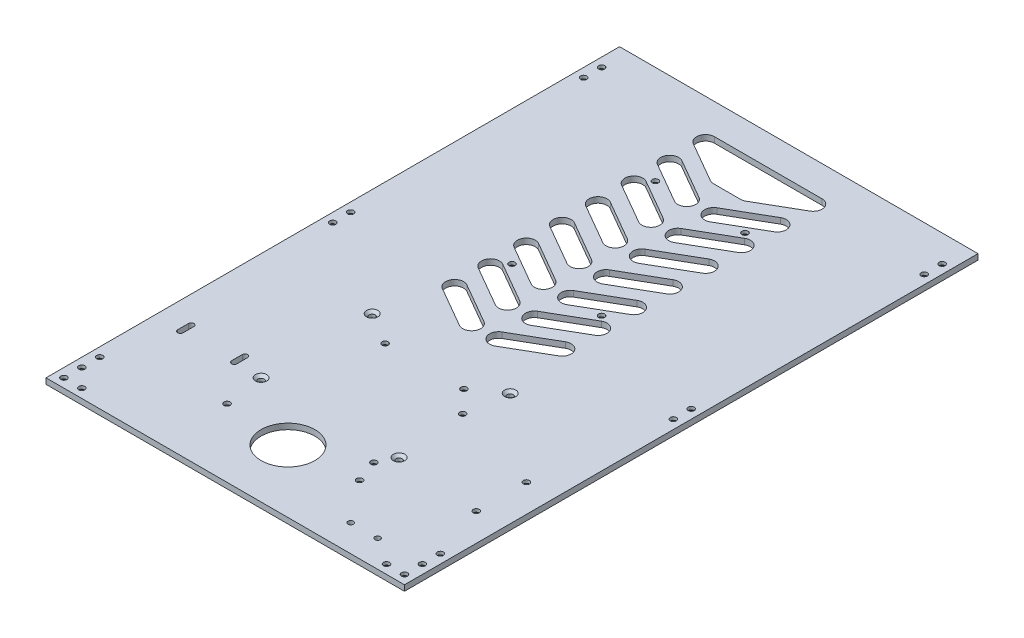
from build123d import *

# Parameters (mm, degrees)
SKETCH1_W                                       = 200
SKETCH1_H                                       = 320
BOSS_EXTRUDE1_DEPTH                             = 3.175
CSK_FOR_M3_FLAT_HEAD_MACHINE_SCREW1_D           = 3.4
CSK_FOR_M3_FLAT_HEAD_MACHINE_SCREW1_CSINK_D     = 6.3
CSK_FOR_M3_FLAT_HEAD_MACHINE_SCREW1_CSINK_ANGLE = 90
CSK_FOR_M3_FLAT_HEAD_MACHINE_SCREW2_D           = 3.4
CSK_FOR_M3_FLAT_HEAD_MACHINE_SCREW2_CSINK_D     = 6.3
CSK_FOR_M3_FLAT_HEAD_MACHINE_SCREW2_CSINK_ANGLE = 90
CSK_FOR_M3_FLAT_HEAD_MACHINE_SCREW3_D           = 3.4
CSK_FOR_M3_FLAT_HEAD_MACHINE_SCREW3_CSINK_D     = 6.3
CSK_FOR_M3_FLAT_HEAD_MACHINE_SCREW3_CSINK_ANGLE = 90
CUT_EXTRUDE1_DEPTH                              = 4.175
LPATTERN1_COUNT                                 = 8
LPATTERN1_PITCH                                 = 20
SKETCH9_R                                       = 15
SKETCH9_R_2                                     = 1.5
CUT_EXTRUDE2_DEPTH                              = 4.175
CSK_FOR_M3_FLAT_HEAD_MACHINE_SCREW4_D           = 3.4
CSK_FOR_M3_FLAT_HEAD_MACHINE_SCREW4_CSINK_D     = 6.3
CSK_FOR_M3_FLAT_HEAD_MACHINE_SCREW4_CSINK_ANGLE = 90
CSK_FOR_M3_FLAT_HEAD_MACHINE_SCREW5_D           = 3.4
CSK_FOR_M3_FLAT_HEAD_MACHINE_SCREW5_CSINK_D     = 6.3
CSK_FOR_M3_FLAT_HEAD_MACHINE_SCREW5_CSINK_ANGLE = 90


with BuildPart() as part:
    # Sketch1 → Boss-Extrude1 (new body)
    with BuildSketch(Plane(origin=(0, 0, 0), x_dir=(1, 0, 0), z_dir=(0, 1, 0))):
        Rectangle(SKETCH1_W, SKETCH1_H)
    extrude(amount=BOSS_EXTRUDE1_DEPTH)

    # CSK for M3 Flat Head Machine Screw1 (through all)
    with Locations(Plane.XZ):
        with Locations((-95, 155), (-85, 155), (-95, 145), (-95, 135), (-95, -145), (-95, -135), (-95, 5), (-95, -5)):
            csk_for_m3_flat_head_machine_screw1 = CounterSinkHole(CSK_FOR_M3_FLAT_HEAD_MACHINE_SCREW1_D / 2, CSK_FOR_M3_FLAT_HEAD_MACHINE_SCREW1_CSINK_D / 2, counter_sink_angle=CSK_FOR_M3_FLAT_HEAD_MACHINE_SCREW1_CSINK_ANGLE)

    # Mirror1: CSK for M3 Flat Head Machine Screw1 across plane
    add(csk_for_m3_flat_head_machine_screw1.mirror(Plane(origin=(0, 0, 0), x_dir=(0, 0, 1), z_dir=(1, 0, 0))), mode=Mode.SUBTRACT)

    # CSK for M3 Flat Head Machine Screw2 (through all)
    with Locations(Plane.XZ):
        with Locations((-25, -105), (25, -105), (25, -25), (-25, -25)):
            CounterSinkHole(CSK_FOR_M3_FLAT_HEAD_MACHINE_SCREW2_D / 2, CSK_FOR_M3_FLAT_HEAD_MACHINE_SCREW2_CSINK_D / 2, counter_sink_angle=CSK_FOR_M3_FLAT_HEAD_MACHINE_SCREW2_CSINK_ANGLE)

    # CSK for M3 Flat Head Machine Screw3 (through all)
    with Locations(Plane(origin=(0, 3.175, 0), x_dir=(-1, 0, 0), z_dir=(0, 1, 0))):
        with Locations((40, 38), (-37, 100), (-37, 38), (40, 100)):
            CounterSinkHole(CSK_FOR_M3_FLAT_HEAD_MACHINE_SCREW3_D / 2, CSK_FOR_M3_FLAT_HEAD_MACHINE_SCREW3_CSINK_D / 2, counter_sink_angle=CSK_FOR_M3_FLAT_HEAD_MACHINE_SCREW3_CSINK_ANGLE)

    # Sketch8 → Cut-Extrude1 (cut, through all)
    with BuildSketch(Plane(origin=(0, 3.175, 0), x_dir=(1, 0, 0), z_dir=(0, 1, 0))):
        with BuildLine():
            Line((-10, -19.330127019), (-32.5, -6.339745962))
            ThreePointArc((-32.5, -6.339745962), (-34.330127019, 0.490381057), (-27.5, 2.320508076))
            Line((-27.5, 2.320508076), (-5, -10.669872981))
            ThreePointArc((-5, -10.669872981), (-3.169872981, -17.5), (-10, -19.330127019))
        make_face()
        with BuildLine():
            Line((10, -19.330127019), (32.5, -6.339745962))
            ThreePointArc((32.5, -6.339745962), (34.330127019, 0.490381057), (27.5, 2.320508076))
            Line((27.5, 2.320508076), (5, -10.669872981))
            ThreePointArc((5, -10.669872981), (3.169872981, -17.5), (10, -19.330127019))
        make_face()
    cut_extrude1 = extrude(amount=-CUT_EXTRUDE1_DEPTH, mode=Mode.SUBTRACT)

    # LPattern1: Cut-Extrude1 ×8
    with Locations(*[(0, 0, -i * LPATTERN1_PITCH) for i in range(1, LPATTERN1_COUNT)]):
        add(cut_extrude1, mode=Mode.SUBTRACT)

    # Sketch9 → Cut-Extrude2 (cut, through all)
    with BuildSketch(Plane(origin=(0, 3.175, 0), x_dir=(1, 0, 0), z_dir=(0, 1, 0))):
        with Locations((0, -125)):
            Circle(SKETCH9_R)
        with Locations((55, -145)):
            Circle(SKETCH9_R_2)
        with Locations((70, -145)):
            Circle(SKETCH9_R_2)
        with BuildLine():
            Line((-7.5, 120), (7.5, 120))
            ThreePointArc((7.5, 120), (8.794095226, 120.170370869), (10, 120.669872981))
            Line((10, 120.669872981), (32.5, 133.660254038))
            ThreePointArc((32.5, 133.660254038), (34.829629131, 139.284476282), (30, 142.990381057))
            Line((30, 142.990381057), (-30, 142.990381057))
            ThreePointArc((-30, 142.990381057), (-34.829629131, 139.284476282), (-32.5, 133.660254038))
            Line((-32.5, 133.660254038), (-10, 120.669872981))
            ThreePointArc((-10, 120.669872981), (-8.794095226, 120.170370869), (-7.5, 120))
        make_face()
        with BuildLine():
            Line((-83.5, -94), (-83.5, -100))
            ThreePointArc((-83.5, -100), (-85, -101.5), (-86.5, -100))
            Line((-86.5, -100), (-86.5, -94))
            ThreePointArc((-86.5, -94), (-85, -92.5), (-83.5, -94))
        make_face()
        with BuildLine():
            Line((-56.5, -94), (-56.5, -100))
            ThreePointArc((-56.5, -100), (-55, -101.5), (-53.5, -100))
            Line((-53.5, -100), (-53.5, -94))
            ThreePointArc((-53.5, -94), (-55, -92.5), (-56.5, -94))
        make_face()
    extrude(amount=-CUT_EXTRUDE2_DEPTH, mode=Mode.SUBTRACT)

    # CSK for M3 Flat Head Machine Screw4 (through all)
    with Locations(Plane.XZ):
        with Locations((84.46, 104.38), (32.39, 109.46), (33.66, 61.2), (84.46, 76.44)):
            CounterSinkHole(CSK_FOR_M3_FLAT_HEAD_MACHINE_SCREW4_D / 2, CSK_FOR_M3_FLAT_HEAD_MACHINE_SCREW4_CSINK_D / 2, counter_sink_angle=CSK_FOR_M3_FLAT_HEAD_MACHINE_SCREW4_CSINK_ANGLE)

    # CSK for M3 Flat Head Machine Screw5 (through all)
    with Locations(Plane.XZ):
        with Locations((-37, 122), (37, 122), (22, 48.822134494), (-22, 48.822134494)):
            CounterSinkHole(CSK_FOR_M3_FLAT_HEAD_MACHINE_SCREW5_D / 2, CSK_FOR_M3_FLAT_HEAD_MACHINE_SCREW5_CSINK_D / 2, counter_sink_angle=CSK_FOR_M3_FLAT_HEAD_MACHINE_SCREW5_CSINK_ANGLE)


solid = part.part
